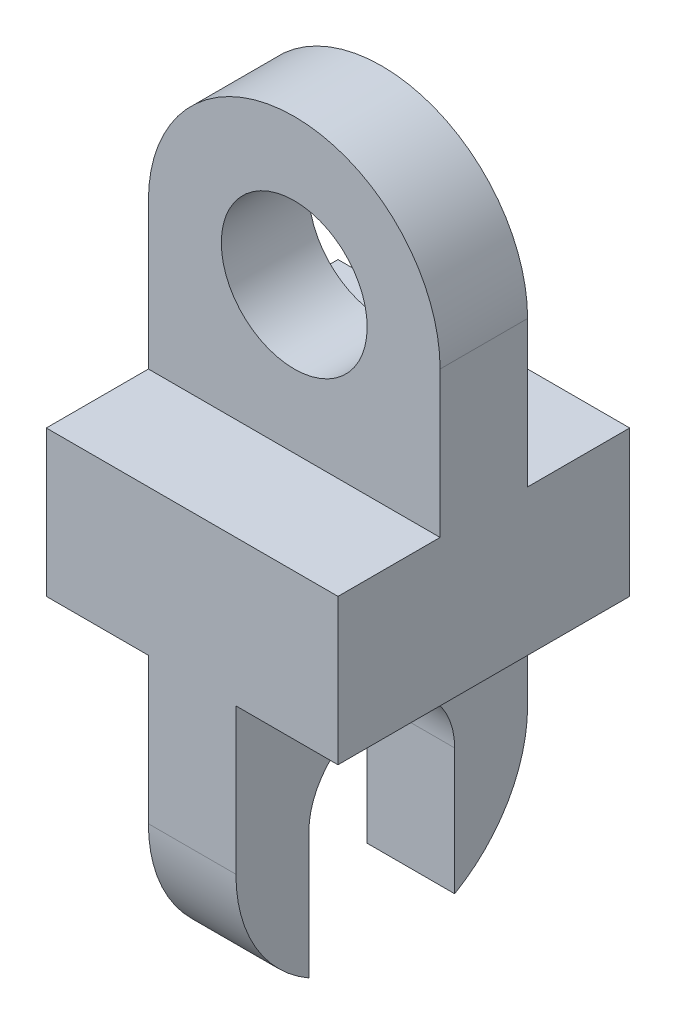
from build123d import *

# Parameters (mm, degrees)
SALIENTE_EXTRUIR1_DEPTH     = 100
CORTAR_EXTRUIR4_DEPTH       = 1
CORTAR_EXTRUIR4_DEPTH_BACK  = 35
CORTAR_EXTRUIR5_DEPTH       = 35
CROQUIS10_R                 = 25
CORTAR_EXTRUIR6_DEPTH       = 36
CORTAR_EXTRUIR6_DEPTH_BACK  = 66
CROQUIS12_W                 = 100
CROQUIS12_H                 = 100
CORTAR_EXTRUIR10_DEPTH      = 1
CORTAR_EXTRUIR10_DEPTH_BACK = 101
SALIENTE_EXTRUIR3_DEPTH     = 100
CROQUIS22_W                 = 100
CROQUIS22_H                 = 100
CORTAR_EXTRUIR12_DEPTH      = 35
CROQUIS23_W                 = 100
CROQUIS23_H                 = 100
CORTAR_EXTRUIR13_DEPTH      = 35
CORTAR_EXTRUIR14_DEPTH      = 36
CORTAR_EXTRUIR14_DEPTH_BACK = 66


with BuildPart() as part:
    # Croquis3 → Saliente-Extruir1 (new body)
    with BuildSketch(Plane.XY):
        with BuildLine():
            Line((-50, 100), (-50, -100))
            Line((-50, -100), (50, -100))
            Line((50, -100), (50, 100))
            ThreePointArc((50, 100), (0, 150), (-50, 100))
        make_face()
    extrude(amount=SALIENTE_EXTRUIR1_DEPTH)

    # Croquis8 → Cortar-Extruir4 (cut, two sides)
    with BuildSketch(Plane.XY.offset(100)) as cortar_extruir4_sk:
        with BuildLine():
            Line((-50, 100), (-50, 50))
            Line((-50, 50), (50, 50))
            Line((50, 50), (50, 100))
            ThreePointArc((50, 100), (0, 150), (-50, 100))
        make_face()
    extrude(amount=CORTAR_EXTRUIR4_DEPTH, mode=Mode.SUBTRACT)
    extrude(cortar_extruir4_sk.sketch, amount=-CORTAR_EXTRUIR4_DEPTH_BACK, mode=Mode.SUBTRACT)

    # Croquis9 → Cortar-Extruir5 (cut)
    with BuildSketch(Plane(origin=(0, 0, 0), x_dir=(-1, 0, 0), z_dir=(0, 0, -1))):
        with BuildLine():
            Line((-50, 100), (-50, 50))
            Line((-50, 50), (50, 50))
            Line((50, 50), (50, 100))
            ThreePointArc((50, 100), (0, 150), (-50, 100))
        make_face()
    extrude(amount=-CORTAR_EXTRUIR5_DEPTH, mode=Mode.SUBTRACT)

    # Croquis10 → Cortar-Extruir6 (cut, two sides)
    with BuildSketch(Plane(origin=(0, 0, 35), x_dir=(-1, 0, 0), z_dir=(0, 0, -1))) as cortar_extruir6_sk:
        with Locations((0, 100)):
            Circle(CROQUIS10_R)
    extrude(amount=CORTAR_EXTRUIR6_DEPTH, mode=Mode.SUBTRACT)
    extrude(cortar_extruir6_sk.sketch, amount=-CORTAR_EXTRUIR6_DEPTH_BACK, mode=Mode.SUBTRACT)

    # Croquis12 → Cortar-Extruir10 (cut, two sides)
    with BuildSketch(Plane.ZY.offset(50)) as cortar_extruir10_sk:
        with Locations((50, -50)):
            Rectangle(CROQUIS12_W, CROQUIS12_H)
    extrude(amount=CORTAR_EXTRUIR10_DEPTH, mode=Mode.SUBTRACT)
    extrude(cortar_extruir10_sk.sketch, amount=-CORTAR_EXTRUIR10_DEPTH_BACK, mode=Mode.SUBTRACT)

    # Croquis17 → Saliente-Extruir3 (add)
    with BuildSketch(Plane.ZY.offset(50)):
        with BuildLine():
            Line((0, 0), (100, 0))
            Line((100, 0), (100, -50))
            ThreePointArc((100, -50), (50, -100), (0, -50))
            Line((0, -50), (0, 0))
        make_face()
    extrude(amount=-SALIENTE_EXTRUIR3_DEPTH)

    # Croquis22 → Cortar-Extruir12 (cut)
    with BuildSketch(Plane.ZY.offset(50)):
        with Locations((50, -50)):
            Rectangle(CROQUIS22_W, CROQUIS22_H)
    extrude(amount=-CORTAR_EXTRUIR12_DEPTH, mode=Mode.SUBTRACT)

    # Croquis23 → Cortar-Extruir13 (cut)
    with BuildSketch(Plane(origin=(50, 0, 0), x_dir=(0, 0, -1), z_dir=(1, 0, 0))):
        with Locations((-50, -50)):
            Rectangle(CROQUIS23_W, CROQUIS23_H)
    extrude(amount=-CORTAR_EXTRUIR13_DEPTH, mode=Mode.SUBTRACT)

    # Croquis24 → Cortar-Extruir14 (cut, two sides)
    with BuildSketch(Plane.ZY.offset(15)) as cortar_extruir14_sk:
        with BuildLine():
            Line((25, -50), (25, -110.42880279))
            Line((25, -110.42880279), (75, -110.42880279))
            Line((75, -110.42880279), (75, -50))
            ThreePointArc((75, -50), (50, -25), (25, -50))
        make_face()
    extrude(amount=CORTAR_EXTRUIR14_DEPTH, mode=Mode.SUBTRACT)
    extrude(cortar_extruir14_sk.sketch, amount=-CORTAR_EXTRUIR14_DEPTH_BACK, mode=Mode.SUBTRACT)


solid = part.part
